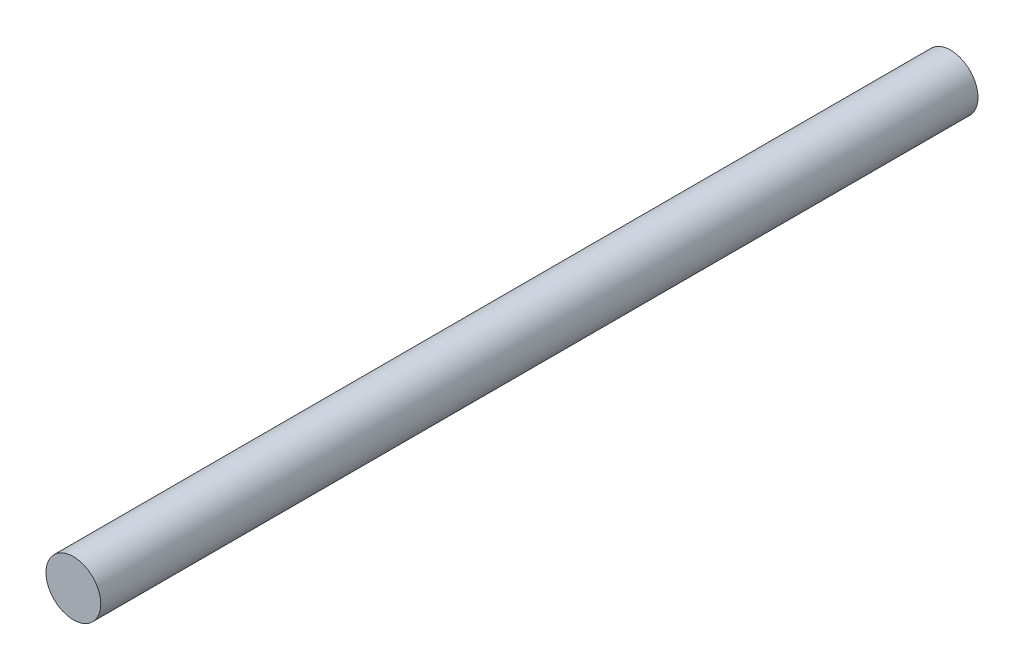
from build123d import *

# Parameters (mm, degrees)
IZIM1_R                     = 6
Y_KSEKLIK_EKSTR_ZYON1_DEPTH = 192


with BuildPart() as part:
    # Çizim1 → Yükseklik-Ekstrüzyon1 (new body)
    with BuildSketch(Plane.XY):
        Circle(IZIM1_R)
    extrude(amount=Y_KSEKLIK_EKSTR_ZYON1_DEPTH)


solid = part.part
